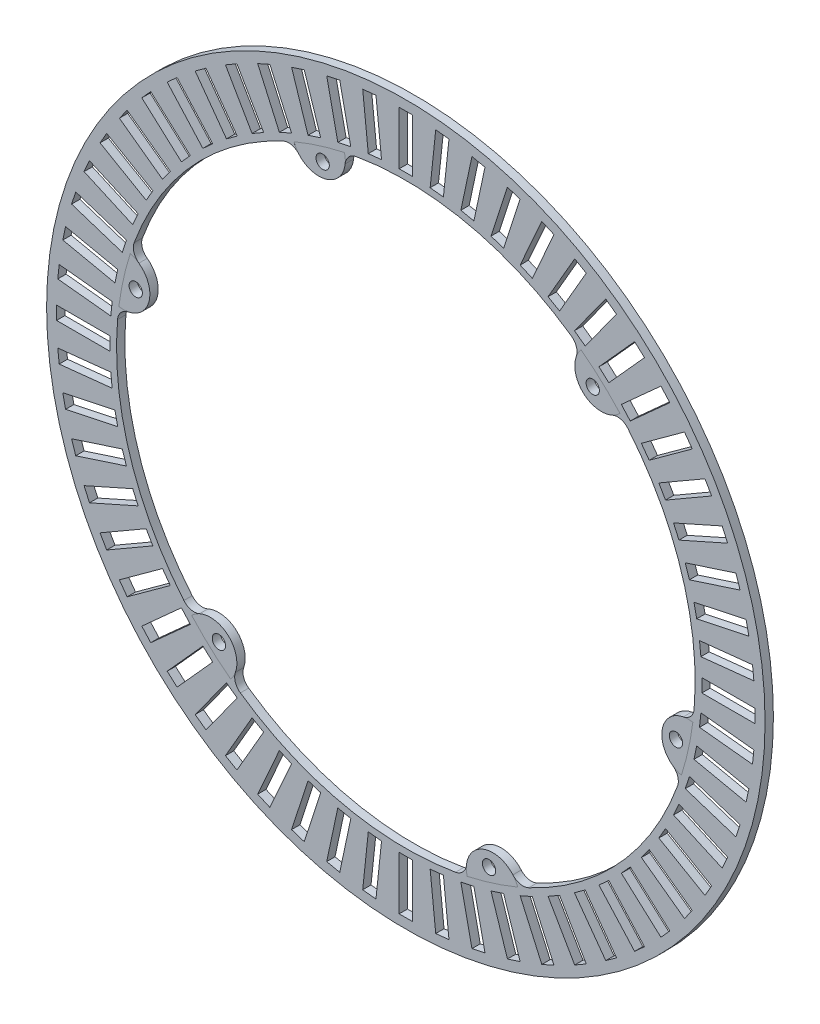
from build123d import *

# Parameters (mm, degrees)
SKETCH1_R                 = 68.500625
SKETCH1_R_2               = 55.165625
BOSS_EXTRUDE1_DEPTH       = 1.5875
SKETCH4_W                 = 2.54
SKETCH4_H                 = 10.16
CUT_EXTRUDE3_DEPTH        = 5.08
CIRPATTERN2_COUNT         = 60
BOSS_EXTRUDE2_START       = -1.5875
BOSS_EXTRUDE2_DEPTH       = 1.587512
FILLET1_R                 = 2.54
CUT_EXTRUDE6_START        = -2.5875121
SKETCH9_R                 = 1.27
CUT_EXTRUDE6_DEPTH        = 3.5875122
CIRPATTERN12_COUNT        = 6
FILLET1_OF_CIRPATTERN12_R = 2.54


with BuildPart() as part:
    # Sketch1 → Boss-Extrude1 (new body)
    with BuildSketch(Plane.XY):
        Circle(SKETCH1_R)
        Circle(SKETCH1_R_2, mode=Mode.SUBTRACT)
    extrude(amount=BOSS_EXTRUDE1_DEPTH)

    # Sketch4 → Cut-Extrude3 (cut)
    with BuildSketch(Plane.XY.offset(1.5875)):
        with Locations((0, 61.515625)):
            Rectangle(SKETCH4_W, SKETCH4_H)
    cut_extrude3 = extrude(amount=-CUT_EXTRUDE3_DEPTH, mode=Mode.SUBTRACT)

    # CirPattern2: Cut-Extrude3 ×60 about axis
    cirpattern2_axis = Axis((0, 0, 0), (0, 0, 1))
    for i in range(1, CIRPATTERN2_COUNT):
        add(cut_extrude3.rotate(cirpattern2_axis, i * 360 / CIRPATTERN2_COUNT), mode=Mode.SUBTRACT)

    # Sketch8 → Boss-Extrude2 (add)
    with BuildSketch(Plane.XY.offset(1.5875).offset(BOSS_EXTRUDE2_START)):
        with BuildLine():
            ThreePointArc((54.724288949, -6.964077875), (48.926905763, -10.846833867), (52.540195701, -16.815885863))
            ThreePointArc((52.540195701, -16.815885863), (53.857979418, -11.940026578), (54.724288949, -6.964077875))
        make_face()
    boss_extrude2 = extrude(amount=BOSS_EXTRUDE2_DEPTH)

    # Fillet1
    fillet1_edges = [part.edges().sort_by_distance(p)[0] for p in [
        (54.724288949, -6.964077875, 0.79375),
        (52.540195701, -16.815885863, 0.79375),
    ]]
    fillet(fillet1_edges, radius=FILLET1_R)

    # Sketch9 → Cut-Extrude6 (cut)
    with BuildSketch(Plane.XY.offset(1.587512).offset(CUT_EXTRUDE6_START)):
        with Locations((51.503613417, -11.418076201)):
            Circle(SKETCH9_R)
    cut_extrude6 = extrude(amount=CUT_EXTRUDE6_DEPTH, mode=Mode.SUBTRACT)

    # CirPattern12: Boss-Extrude2, Cut-Extrude6 ×6 about axis
    cirpattern12_axis = Axis((0, 0, 0), (0, 0, 1))
    for i in range(1, CIRPATTERN12_COUNT):
        add(boss_extrude2.rotate(cirpattern12_axis, i * 360 / CIRPATTERN12_COUNT))
        add(cut_extrude6.rotate(cirpattern12_axis, i * 360 / CIRPATTERN12_COUNT), mode=Mode.SUBTRACT)

    # Fillet1 of CirPattern12
    fillet1_of_cirpattern12_edges = [part.edges().sort_by_distance(p)[0] for p in [
        (33.393212829, 43.910585496, 0.79375),
        (40.833082195, 37.093201266, 0.79375),
        (-21.33107612, 50.874663372, 0.79375),
        (-11.707113506, 53.909087128, 0.79375),
        (-54.724288949, 6.964077875, 0.79375),
        (-52.540195701, 16.815885863, 0.79375),
        (-33.393212829, -43.910585496, 0.79375),
        (-40.833082195, -37.093201266, 0.79375),
        (21.33107612, -50.874663372, 0.79375),
        (11.707113506, -53.909087128, 0.79375),
    ]]
    fillet(fillet1_of_cirpattern12_edges, radius=FILLET1_OF_CIRPATTERN12_R)


solid = part.part
